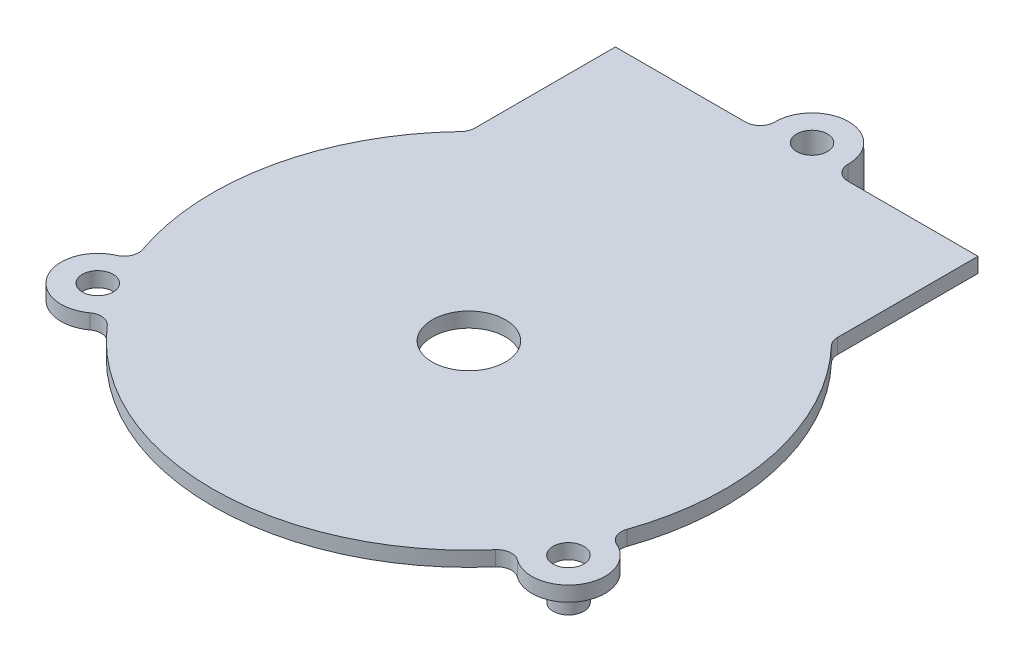
from build123d import *

# Parameters (mm, degrees)
SKETCH13_R                 = 35
BOSS_EXTRUDE3_DEPTH        = 2.032
BOSS_EXTRUDE4_DEPTH        = 2.032
SKETCH15_R                 = 4.995989681
SKETCH15_R_2               = 2.096052025
BOSS_EXTRUDE11_DEPTH       = 5.588
SKETCH14_6_R               = 4.995125596
BOSS_EXTRUDE12_DEPTH       = 2.032
SKETCH14_8_R               = 2.101679538
BOSS_EXTRUDE14_DEPTH       = 5.588
F_4_2_4_2_DIAMETER_HOLE1_D = 4.2
SKETCH14_11_R              = 4.999542267
BOSS_EXTRUDE15_DEPTH       = 2.032
F_4_2_4_2_DIAMETER_HOLE2_D = 4.2
FILLET4_R                  = 2
FILLET6_R                  = 2
FILLET7_R                  = 2
FILLET8_R                  = 2
FILLET9_R                  = 2
FILLET10_R                 = 2
FILLET11_R                 = 2
FILLET12_R                 = 2
SKETCH28_R                 = 5
CUT_EXTRUDE1_DEPTH         = 2.032


with BuildPart() as part:
    # Sketch13 → Boss-Extrude3 (new body)
    with BuildSketch(Plane(origin=(0, 0, 0), x_dir=(1, 0, 0), z_dir=(0, 1, 0))):
        Circle(SKETCH13_R)
    extrude(amount=BOSS_EXTRUDE3_DEPTH)

    # Sketch14 → Boss-Extrude4 (add)
    with BuildSketch(Plane(origin=(0, 2.032, 0), x_dir=(1, 0, 0), z_dir=(0, 1, 0))):
        Polygon((-24.747800113, 24.749674535), (24.747650593, 24.749824043), (24.747590193, 44.74538209), (-24.747860512, 44.745232583), align=None)
    extrude(amount=-BOSS_EXTRUDE4_DEPTH)

    # Sketch15 → Boss-Extrude11 (add)
    with BuildSketch(Plane(origin=(0, 2.032, 0), x_dir=(1, 0, 0), z_dir=(0, 1, 0))):
        with Locations((0, 46.841359357)):
            Circle(SKETCH15_R)
        with Locations((0, 46.841359357)):
            Circle(SKETCH15_R_2, mode=Mode.SUBTRACT)
    extrude(amount=-BOSS_EXTRUDE11_DEPTH)

    # Sketch14_6 → Boss-Extrude12 (add)
    with BuildSketch(Plane(origin=(0, 2.032, 0), x_dir=(1, 0, 0), z_dir=(0, 1, 0))):
        with Locations((32.136488635, -18.541287958)):
            Circle(SKETCH14_6_R)
    extrude(amount=-BOSS_EXTRUDE12_DEPTH)

    # Sketch14_8 → Boss-Extrude14 (add, through all)
    with BuildSketch(Plane(origin=(0, 2.032, 0), x_dir=(1, 0, 0), z_dir=(0, 1, 0))):
        with Locations((32.136488635, -18.541287958)):
            Circle(SKETCH14_8_R)
    extrude(amount=-BOSS_EXTRUDE14_DEPTH)

    # Ø4.2 (4.2) Diameter Hole1 (through all)
    with Locations(Plane(origin=(0, 2.032, 0), x_dir=(1, 0, 0), z_dir=(0, 1, 0))):
        with Locations((32.124781199, -18.535617326)):
            Hole(F_4_2_4_2_DIAMETER_HOLE1_D / 2)

    # Sketch14_11 → Boss-Extrude15 (add)
    with BuildSketch(Plane(origin=(0, 2.032, 0), x_dir=(1, 0, 0), z_dir=(0, 1, 0))):
        with Locations((-32.146455556, -18.516181944)):
            Circle(SKETCH14_11_R)
    extrude(amount=-BOSS_EXTRUDE15_DEPTH)

    # Ø4.2 (4.2) Diameter Hole2 (through all)
    with Locations(Plane(origin=(0, 2.032, 0), x_dir=(1, 0, 0), z_dir=(0, 1, 0))):
        with Locations((-32.148016614, -18.508796165)):
            Hole(F_4_2_4_2_DIAMETER_HOLE2_D / 2)

    # Fillet4
    fillet4_edges = [part.edges().sort_by_distance(p)[0] for p in [
        (-24.747800113, 1.016, -24.749674535),
    ]]
    fillet(fillet4_edges, radius=FILLET4_R)

    # Fillet6
    fillet6_edges = [part.edges().sort_by_distance(p)[0] for p in [
        (-32.283887234, 1.016, 13.518528953),
    ]]
    fillet(fillet6_edges, radius=FILLET6_R)

    # Fillet7
    fillet7_edges = [part.edges().sort_by_distance(p)[0] for p in [
        (-27.892412635, 1.016, 21.142689456),
    ]]
    fillet(fillet7_edges, radius=FILLET7_R)

    # Fillet8
    fillet8_edges = [part.edges().sort_by_distance(p)[0] for p in [
        (27.881240805, 1.016, 21.157419766),
    ]]
    fillet(fillet8_edges, radius=FILLET8_R)

    # Fillet9
    fillet9_edges = [part.edges().sort_by_distance(p)[0] for p in [
        (32.27153567, 1.016, 13.547988245),
    ]]
    fillet(fillet9_edges, radius=FILLET9_R)

    # Fillet10
    fillet10_edges = [part.edges().sort_by_distance(p)[0] for p in [
        (24.747650593, 1.016, -24.749824043),
    ]]
    fillet(fillet10_edges, radius=FILLET10_R)

    # Fillet11
    fillet11_edges = [part.edges().sort_by_distance(p)[0] for p in [
        (4.535034317, 1.016, -44.745321036),
    ]]
    fillet(fillet11_edges, radius=FILLET11_R)

    # Fillet12
    fillet12_edges = [part.edges().sort_by_distance(p)[0] for p in [
        (-4.535021654, 1.016, -44.745293638),
    ]]
    fillet(fillet12_edges, radius=FILLET12_R)

    # Sketch28 → Cut-Extrude1 (cut)
    with BuildSketch(Plane(origin=(0, 2.032, 0), x_dir=(1, 0, 0), z_dir=(0, 1, 0))):
        Circle(SKETCH28_R)
    extrude(amount=-CUT_EXTRUDE1_DEPTH, mode=Mode.SUBTRACT)


solid = part.part
